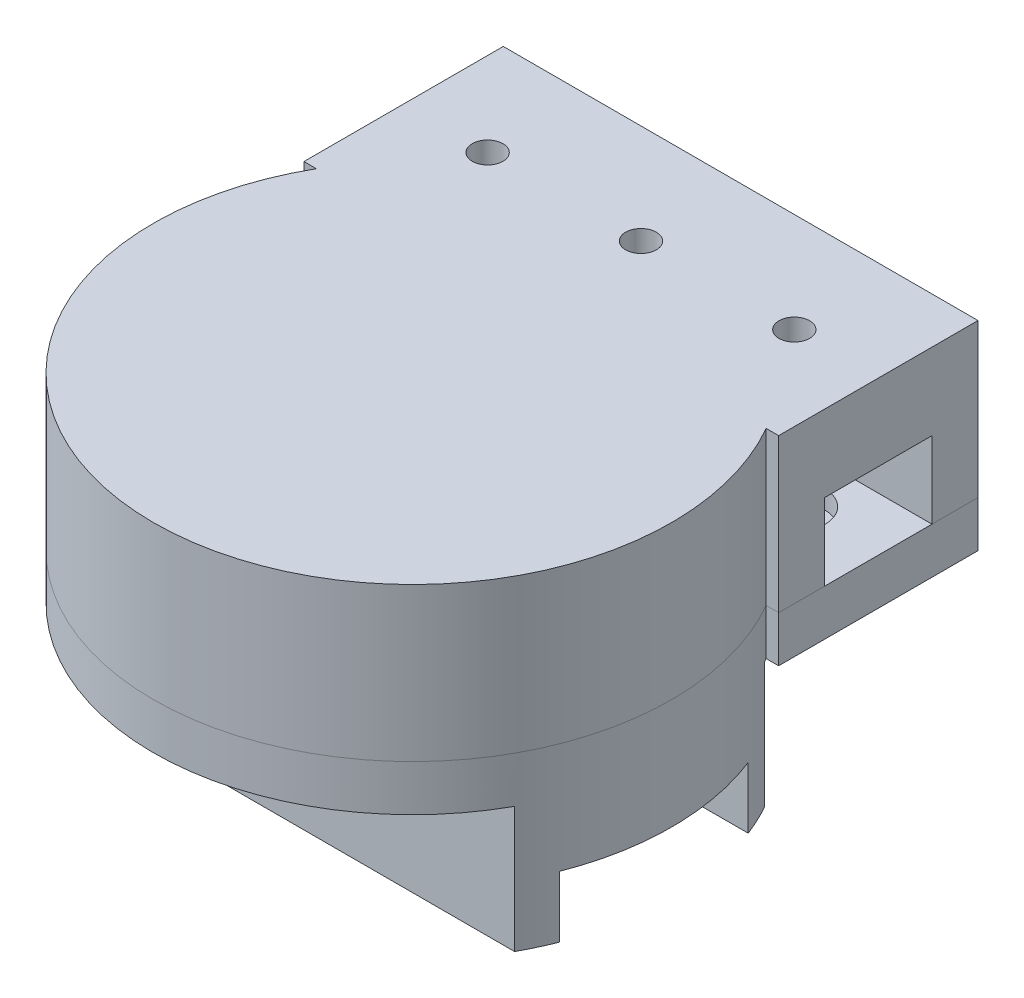
from build123d import *

# Parameters (mm, degrees)
BOSS_EXTRUDE1_DEPTH      = 5
SKETCH1_W                = 6
SKETCH1_H                = 3
BOSS_EXTRUDE1_2_DEPTH    = 5
BOSS_EXTRUDE1_3_DEPTH    = 5
SKETCH1_4_R              = 2
BOSS_EXTRUDE2_DEPTH      = 5
SKETCH1_7_R              = 2
BOSS_EXTRUDE6_DEPTH      = 5
BOSS_EXTRUDE6_DEPTH_BACK = 2
BOSS_EXTRUDE7_DEPTH      = 3
SKETCH5_R                = 1
CUT_EXTRUDE1_DEPTH       = 15
SKETCH6_R                = 2
CUT_EXTRUDE2_DEPTH       = 6.2
CUT_EXTRUDE2_DEPTH_BACK  = 1
SKETCH1_9_W              = 18.956009986
SKETCH1_9_H              = 3
BOSS_EXTRUDE9_DEPTH      = 1.6
SKETCH3_5_R              = 5.35
CUT_EXTRUDE3_DEPTH       = 5
SKETCH11_R               = 0.75
CUT_EXTRUDE5_DEPTH       = 6
BOSS_EXTRUDE11_DEPTH     = 4.2
BOSS_EXTRUDE12_DEPTH     = 4
SKETCH11_4_R             = 1.25
SKETCH11_4_R_2           = 0.75
CUT_EXTRUDE6_DEPTH       = 1
SKETCH15_R               = 1
CUT_EXTRUDE7_DEPTH       = 3


with BuildPart() as part:
    # Sketch1 → Boss-Extrude1 (new body)
    with BuildSketch(Plane(origin=(0, 0, 0), x_dir=(1, 0, 0), z_dir=(0, 1, 0))):
        with BuildLine():
            Line((-15.478004993, 8.397780108), (-14.665854535, 8.397780108))
            ThreePointArc((-14.665854535, 8.397780108), (0, -16.9), (14.665854535, 8.397780108))
            Line((14.665854535, 8.397780108), (15.478004993, 8.397780108))
            Line((15.478004993, 8.397780108), (15.478004993, 11.397780108))
            Line((15.478004993, 11.397780108), (7.956167959, 11.397780108))
            ThreePointArc((7.956167959, 11.397780108), (0, -13.9), (-7.956167959, 11.397780108))
            Line((-7.956167959, 11.397780108), (-15.478004993, 11.397780108))
            Line((-15.478004993, 11.397780108), (-15.478004993, 8.397780108))
        make_face()
    extrude(amount=-BOSS_EXTRUDE1_DEPTH)



with BuildPart() as body_2:
    # Sketch1 → Boss-Extrude1 2 (new body)
    with BuildSketch(Plane(origin=(0, 0, 0), x_dir=(1, 0, 0), z_dir=(0, 1, 0))):
        with Locations((-12.478004993, 19.897780108)):
            Rectangle(SKETCH1_W, SKETCH1_H)
    extrude(amount=-BOSS_EXTRUDE1_2_DEPTH)


with BuildPart() as body_3:
    # Sketch1 → Boss-Extrude1 3 (new body)
    with BuildSketch(Plane(origin=(0, 0, 0), x_dir=(1, 0, 0), z_dir=(0, 1, 0))):
        with Locations((12.478004993, 19.897780108)):
            Rectangle(SKETCH1_W, SKETCH1_H)
    extrude(amount=-BOSS_EXTRUDE1_3_DEPTH)


with BuildPart() as part_1:
    add(part.part)

    add(body_2.part)  # Boss-Extrude2 merges body 2

    add(body_3.part)  # Boss-Extrude2 merges body 3
    # Sketch1_4 → Boss-Extrude2 (add)
    with BuildSketch(Plane(origin=(0, 0, 0), x_dir=(1, 0, 0), z_dir=(0, 1, 0))):
        with BuildLine():
            Line((-15.478004993, 21.397780108), (-15.478004993, 8.397780108))
            Line((-15.478004993, 8.397780108), (-14.665854535, 8.397780108))
            ThreePointArc((-14.665854535, 8.397780108), (0, -16.9), (14.665854535, 8.397780108))
            Line((14.665854535, 8.397780108), (15.478004993, 8.397780108))
            Line((15.478004993, 8.397780108), (15.478004993, 21.397780108))
            Line((15.478004993, 21.397780108), (-15.478004993, 21.397780108))
        make_face()
        Circle(SKETCH1_4_R, mode=Mode.SUBTRACT)
    extrude(amount=BOSS_EXTRUDE2_DEPTH)

    # Sketch1_7 → Boss-Extrude6 (add, two sides)
    with BuildSketch(Plane(origin=(0, 0, 0), x_dir=(1, 0, 0), z_dir=(0, 1, 0))) as boss_extrude6_sk:
        Circle(SKETCH1_7_R)
    extrude(amount=BOSS_EXTRUDE6_DEPTH)
    extrude(boss_extrude6_sk.sketch, amount=-BOSS_EXTRUDE6_DEPTH_BACK)


with BuildPart() as body_2_2:
    # Sketch3 → Boss-Extrude7 (new body)
    with BuildSketch(Plane.XZ.offset(5)):
        with BuildLine():
            Line((-14.665854535, -8.397780108), (-15.478004993, -8.397780108))
            Line((-15.478004993, -8.397780108), (-15.478004993, -21.397780108))
            Line((-15.478004993, -21.397780108), (15.478004993, -21.397780108))
            Line((15.478004993, -21.397780108), (15.478004993, -8.397780108))
            Line((15.478004993, -8.397780108), (14.665854535, -8.397780108))
            ThreePointArc((14.665854535, -8.397780108), (0, 16.9), (-14.665854535, -8.397780108))
        make_face()
    extrude(amount=BOSS_EXTRUDE7_DEPTH)


with BuildPart() as cut_extrude1_tool:
    # Sketch5 → Cut-Extrude1 (new body)
    with BuildSketch(Plane(origin=(0, 5, 0), x_dir=(1, 0, 0), z_dir=(0, 1, 0))):
        with Locations((0, 14.897780108)):
            Circle(SKETCH5_R)
        with Locations((10, 14.897780108)):
            Circle(SKETCH5_R)
        with Locations((-10, 14.897780108)):
            Circle(SKETCH5_R)
    extrude(amount=-CUT_EXTRUDE1_DEPTH)


with BuildPart() as part_2:
    add(part_1.part)

    # Cut-Extrude1: cut by cut_extrude1_tool
    add(cut_extrude1_tool.part, mode=Mode.SUBTRACT)


with BuildPart() as body_2_2_1:
    add(body_2_2.part)

    # Cut-Extrude1: cut by cut_extrude1_tool
    add(cut_extrude1_tool.part, mode=Mode.SUBTRACT)


with BuildPart() as cut_extrude2_tool:
    # Sketch6 → Cut-Extrude2 (new body, two sides)
    with BuildSketch(Plane.XZ) as cut_extrude2_sk:
        with Locations((-10, -14.897780108)):
            Circle(SKETCH6_R)
        with Locations((0, -14.897780108)):
            Circle(SKETCH6_R)
        with Locations((10, -14.897780108)):
            Circle(SKETCH6_R)
    extrude(amount=CUT_EXTRUDE2_DEPTH)
    extrude(cut_extrude2_sk.sketch, amount=-CUT_EXTRUDE2_DEPTH_BACK)


with BuildPart() as part_3:
    add(part_2.part)

    # Cut-Extrude2: cut by cut_extrude2_tool
    add(cut_extrude2_tool.part, mode=Mode.SUBTRACT)

    # Sketch1_9 → Boss-Extrude9 (add)
    with BuildSketch(Plane(origin=(0, 0, 0), x_dir=(1, 0, 0), z_dir=(0, 1, 0))):
        with Locations((0, 19.897780108)):
            Rectangle(SKETCH1_9_W, SKETCH1_9_H)
    extrude(amount=-BOSS_EXTRUDE9_DEPTH)


with BuildPart() as body_2_2_2:
    add(body_2_2_1.part)

    # Cut-Extrude2: cut by cut_extrude2_tool
    add(cut_extrude2_tool.part, mode=Mode.SUBTRACT)

    # Sketch3_5 → Cut-Extrude3 (cut)
    with BuildSketch(Plane.XZ.offset(5)):
        Circle(SKETCH3_5_R)
    extrude(amount=CUT_EXTRUDE3_DEPTH, mode=Mode.SUBTRACT)


with BuildPart() as cut_extrude5_tool:
    # Sketch11 → Cut-Extrude5 (new body)
    with BuildSketch(Plane.XZ.offset(8)):
        with Locations((-13.478004993, -9.897780108)):
            Circle(SKETCH11_R)
        with Locations((13.478004993, -9.897780108)):
            Circle(SKETCH11_R)
        with Locations((13.478004993, -19.897780108)):
            Circle(SKETCH11_R)
        with Locations((-13.478004993, -19.897780108)):
            Circle(SKETCH11_R)
        with Locations((0, 15.271275141)):
            Circle(SKETCH11_R)
    extrude(amount=-CUT_EXTRUDE5_DEPTH)


with BuildPart() as part_4:
    add(part_3.part)

    # Cut-Extrude5: cut by cut_extrude5_tool
    add(cut_extrude5_tool.part, mode=Mode.SUBTRACT)

    # Sketch15 → Cut-Extrude7 (cut)
    with BuildSketch(Plane(origin=(0, 0, -21.397780108), x_dir=(-1, 0, 0), z_dir=(0, 0, -1))):
        with Locations((0, 2.33872342)):
            Circle(SKETCH15_R)
        with Locations((10, 2.33872342)):
            Circle(SKETCH15_R)
        with Locations((-10, 2.33872342)):
            Circle(SKETCH15_R)
    extrude(amount=-CUT_EXTRUDE7_DEPTH, mode=Mode.SUBTRACT)


with BuildPart() as body_2_2_3:
    add(body_2_2_2.part)

    # Cut-Extrude5: cut by cut_extrude5_tool
    add(cut_extrude5_tool.part, mode=Mode.SUBTRACT)

    # Sketch12 → Boss-Extrude11 (add)
    with BuildSketch(Plane.XZ.offset(8)):
        with BuildLine():
            Line((-10.75, -8.15), (14.804982269, -8.15))
            ThreePointArc((14.804982269, -8.15), (16.9, 0), (14.804982269, 8.15))
            Line((14.804982269, 8.15), (-10.75, 8.15))
            Line((-10.75, 8.15), (-10.75, 0.49803322))
            Line((-10.75, 0.49803322), (-9.895643924, 0.49803322))
            ThreePointArc((-9.895643924, 0.49803322), (-7.5, -0.00196678), (-9.895643924, -0.50196678))
            Line((-9.895643924, -0.50196678), (-10.75, -0.50196678))
            Line((-10.75, -0.50196678), (-10.75, -8.15))
        make_face()
        with BuildLine():
            Line((5.423329236, 2.9), (5.75, 2.9))
            ThreePointArc((5.75, 2.9), (8.65, 0), (5.75, -2.9))
            Line((5.75, -2.9), (5.423329236, -2.9))
            ThreePointArc((5.423329236, -2.9), (-6.15, 0), (5.423329236, 2.9))
        make_face(mode=Mode.SUBTRACT)
    extrude(amount=BOSS_EXTRUDE11_DEPTH)

    # Sketch13 → Boss-Extrude12 (add)
    with BuildSketch(Plane.XZ.offset(12.2)):
        with BuildLine():
            Line((-10.75, -8.15), (14.804982269, -8.15))
            ThreePointArc((14.804982269, -8.15), (15.305827078, -7.165309307), (15.74126742, -6.15))
            Line((15.74126742, -6.15), (0, -6.15))
            ThreePointArc((0, -6.15), (-6.15, 1e-08), (2.1e-08, 6.15))
            Line((2.1e-08, 6.15), (15.74126742, 6.15))
            ThreePointArc((15.74126742, 6.15), (15.305827078, 7.165309307), (14.804982269, 8.15))
            Line((14.804982269, 8.15), (-10.75, 8.15))
            Line((-10.75, 8.15), (-10.75, 0.49803322))
            Line((-10.75, 0.49803322), (-9.895643924, 0.49803322))
            ThreePointArc((-9.895643924, 0.49803322), (-7.5, -0.00196678), (-9.895643924, -0.50196678))
            Line((-9.895643924, -0.50196678), (-10.75, -0.50196678))
            Line((-10.75, -0.50196678), (-10.75, -8.15))
        make_face()
    extrude(amount=BOSS_EXTRUDE12_DEPTH)

    # Sketch11_4 → Cut-Extrude6 (cut)
    with BuildSketch(Plane.XZ.offset(8)):
        with Locations((13.478004993, -19.897780108)):
            Circle(SKETCH11_4_R)
        with Locations((13.478004993, -19.897780108)):
            Circle(SKETCH11_4_R_2, mode=Mode.SUBTRACT)
        with Locations((13.478004993, -9.897780108)):
            Circle(SKETCH11_4_R)
        with Locations((13.478004993, -9.897780108)):
            Circle(SKETCH11_4_R_2, mode=Mode.SUBTRACT)
        with Locations((-13.478004993, -9.897780108)):
            Circle(SKETCH11_4_R)
        with Locations((-13.478004993, -9.897780108)):
            Circle(SKETCH11_4_R_2, mode=Mode.SUBTRACT)
        with Locations((-13.478004993, -19.897780108)):
            Circle(SKETCH11_4_R)
        with Locations((-13.478004993, -19.897780108)):
            Circle(SKETCH11_4_R_2, mode=Mode.SUBTRACT)
        with Locations((0, 15.271275141)):
            Circle(SKETCH11_4_R)
        with Locations((0, 15.271275141)):
            Circle(SKETCH11_4_R_2, mode=Mode.SUBTRACT)
    extrude(amount=-CUT_EXTRUDE6_DEPTH, mode=Mode.SUBTRACT)


solid = Compound([part_4.part, body_2_2_3.part])
